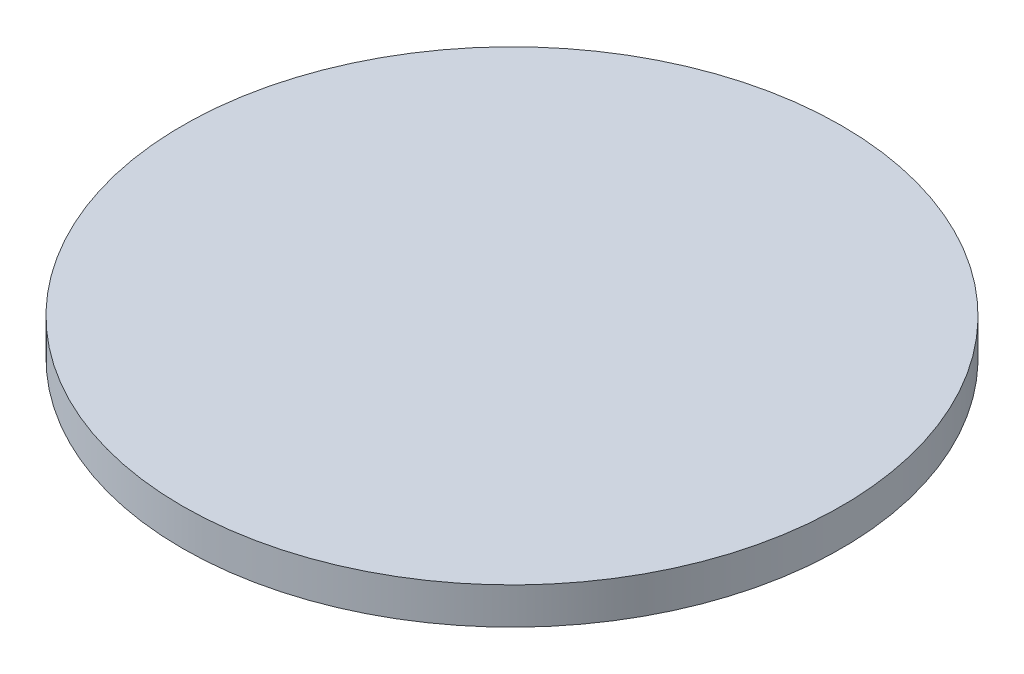
from build123d import *

# Parameters (mm, degrees)
SKETCH1_R           = 27
BOSS_EXTRUDE1_DEPTH = 3


with BuildPart() as part:
    # Sketch1 → Boss-Extrude1 (new body)
    with BuildSketch(Plane(origin=(0, 0, 0), x_dir=(1, 0, 0), z_dir=(0, 1, 0))):
        Circle(SKETCH1_R)
    extrude(amount=BOSS_EXTRUDE1_DEPTH)


solid = part.part
